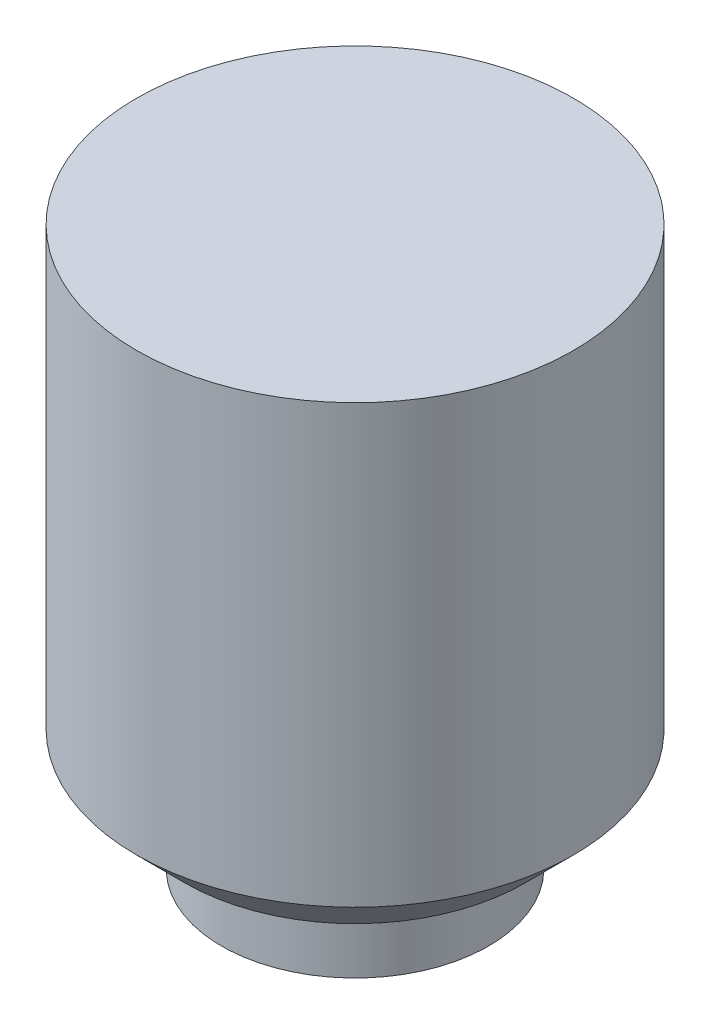
from build123d import *

# Parameters (mm, degrees)
SKETCH1_R           = 4.5
BOSS_EXTRUDE1_DEPTH = 10
CUT_EXTRUDE1_DEPTH  = 3
SKETCH3_R           = 2.75
SKETCH3_R_2         = 1.75
BOSS_EXTRUDE2_DEPTH = 1.5
CHAMFER1_SIZE       = 1


with BuildPart() as part:
    # Sketch1 → Boss-Extrude1 (new body)
    with BuildSketch(Plane(origin=(0, 0, 0), x_dir=(1, 0, 0), z_dir=(0, 1, 0))):
        Circle(SKETCH1_R)
    extrude(amount=BOSS_EXTRUDE1_DEPTH)

    # Sketch2 → Cut-Extrude1 (cut)
    with BuildSketch(Plane.XZ):
        with BuildLine():
            Line((-1, 1.05), (1, 1.05))
            ThreePointArc((1, 1.05), (0, -1.45), (-1, 1.05))
        make_face()
    extrude(amount=-CUT_EXTRUDE1_DEPTH, mode=Mode.SUBTRACT)

    # Sketch3 → Boss-Extrude2 (add)
    with BuildSketch(Plane.XZ):
        Circle(SKETCH3_R)
        Circle(SKETCH3_R_2, mode=Mode.SUBTRACT)
    extrude(amount=BOSS_EXTRUDE2_DEPTH)

    # Chamfer1
    chamfer1_edges = [part.edges().sort_by_distance(p)[0] for p in [
        (-4.5, 0, 0),
    ]]
    chamfer(chamfer1_edges, length=CHAMFER1_SIZE)


solid = part.part
